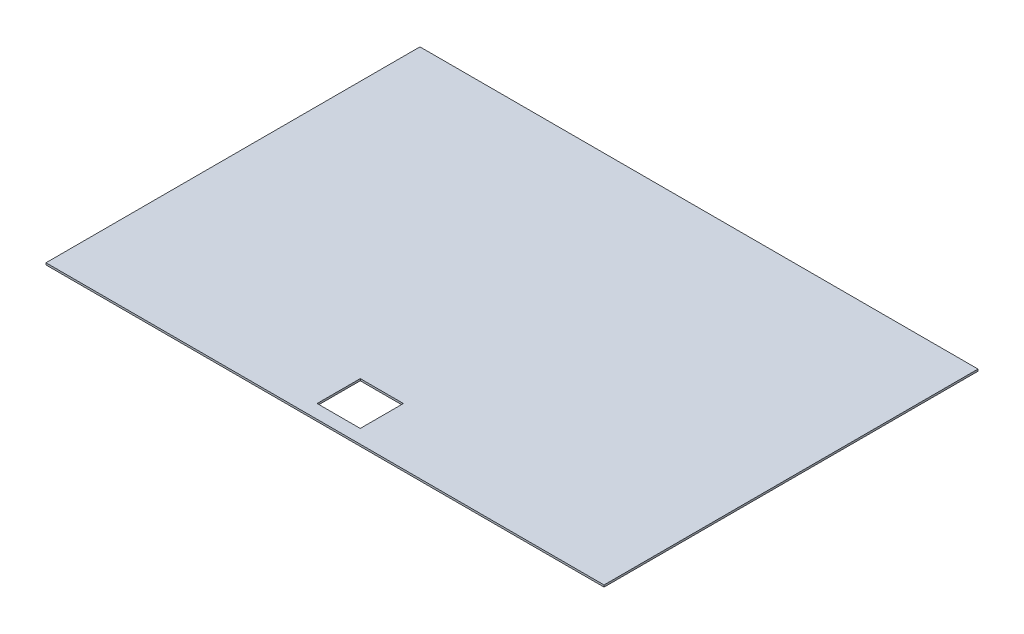
from build123d import *

# Parameters (mm, degrees)
SKETCH1_W               = 923.925
SKETCH1_H               = 619.125
BOSS_EXTRUDE1_DEPTH     = 3.175
SKETCH2_W               = 71.4375
SKETCH2_H               = 71.4375
CUT_EXTRUDE1_DEPTH      = 1
CUT_EXTRUDE1_DEPTH_BACK = 4.175


with BuildPart() as part:
    # Sketch1 → Boss-Extrude1 (new body)
    with BuildSketch(Plane(origin=(0, 0, 0), x_dir=(1, 0, 0), z_dir=(0, 1, 0))):
        with Locations((461.9625, 309.5625)):
            Rectangle(SKETCH1_W, SKETCH1_H)
    extrude(amount=BOSS_EXTRUDE1_DEPTH)

    # Sketch2 → Cut-Extrude1 (cut, two sides)
    with BuildSketch(Plane(origin=(0, 3.175, 0), x_dir=(1, 0, 0), z_dir=(0, 1, 0))) as cut_extrude1_sk:
        with Locations((461.9625, 58.32475)):
            Rectangle(SKETCH2_W, SKETCH2_H)
    extrude(amount=CUT_EXTRUDE1_DEPTH, mode=Mode.SUBTRACT)
    extrude(cut_extrude1_sk.sketch, amount=-CUT_EXTRUDE1_DEPTH_BACK, mode=Mode.SUBTRACT)


solid = part.part
